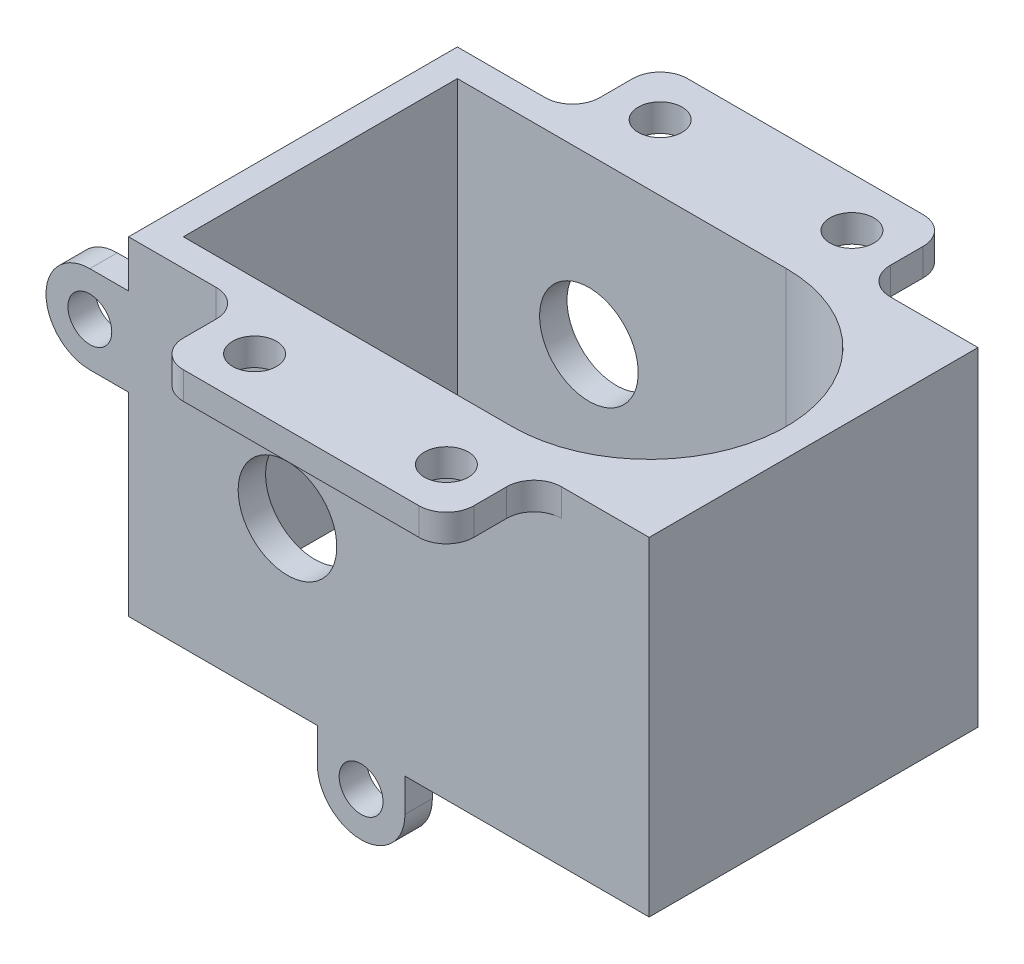
from build123d import *

# Parameters (mm, degrees)
CROQUIS1_W              = 30
CROQUIS1_H              = 30
SALIENTE_EXTRUIR1_DEPTH = 30
CROQUIS2_R              = 12.5
CORTAR_EXTRUIR1_DEPTH   = 30
CROQUIS4_W              = 30
CROQUIS4_H              = 30
SALIENTE_EXTRUIR5_DEPTH = 17.5
CROQUIS6_W              = 30
CROQUIS6_H              = 25
CORTAR_EXTRUIR3_DEPTH   = 37.5
CROQUIS7_R              = 4.5
CORTAR_EXTRUIR5_DEPTH   = 37.5
CROQUIS8_R              = 2
SALIENTE_EXTRUIR6_DEPTH = 2.5
CROQUIS9_W              = 26.5
CROQUIS9_H              = 8
CROQUIS9_R              = 2
SALIENTE_EXTRUIR7_DEPTH = 2.5
REDONDEO1_R             = 2.5


with BuildPart() as part:
    # Croquis1 → Saliente-Extruir1 (new body)
    with BuildSketch(Plane(origin=(0, 0, 0), x_dir=(1, 0, 0), z_dir=(0, 1, 0))):
        Rectangle(CROQUIS1_W, CROQUIS1_H)
    extrude(amount=SALIENTE_EXTRUIR1_DEPTH)

    # Croquis2 → Cortar-Extruir1 (cut)
    with BuildSketch(Plane(origin=(0, 30, 0), x_dir=(1, 0, 0), z_dir=(0, 1, 0))):
        Circle(CROQUIS2_R)
    extrude(amount=-CORTAR_EXTRUIR1_DEPTH, mode=Mode.SUBTRACT)

    # Croquis4 → Saliente-Extruir5 (add)
    with BuildSketch(Plane.ZY.offset(15)):
        with Locations((0, 15)):
            Rectangle(CROQUIS4_W, CROQUIS4_H)
    extrude(amount=SALIENTE_EXTRUIR5_DEPTH)

    # Croquis6 → Cortar-Extruir3 (cut)
    with BuildSketch(Plane(origin=(0, 30, 0), x_dir=(1, 0, 0), z_dir=(0, 1, 0))):
        with Locations((-15, 0)):
            Rectangle(CROQUIS6_W, CROQUIS6_H)
    extrude(amount=-CORTAR_EXTRUIR3_DEPTH, mode=Mode.SUBTRACT)

    # Croquis7 → Cortar-Extruir5 (cut)
    with BuildSketch(Plane(origin=(0, 0, -15), x_dir=(-1, 0, 0), z_dir=(0, 0, -1))):
        with Locations((18, 15)):
            Circle(CROQUIS7_R)
    extrude(amount=-CORTAR_EXTRUIR5_DEPTH, mode=Mode.SUBTRACT)

    # Croquis8 → Saliente-Extruir6 (add)
    with BuildSketch(Plane.XY.offset(15)):
        with BuildLine():
            Line((-36.03122292, 25.717514421), (-32.5, 25.717514421))
            Line((-32.5, 25.717514421), (-32.5, 17.717514421))
            Line((-32.5, 17.717514421), (-36.03122292, 17.717514421))
            ThreePointArc((-36.03122292, 17.717514421), (-40.03122292, 21.717514421), (-36.03122292, 25.717514421))
        make_face()
        with Locations((-36.03122292, 21.717514421)):
            Circle(CROQUIS8_R, mode=Mode.SUBTRACT)
        with BuildLine():
            Line((-15.282485579, -3.03122292), (-15.282485579, 0))
            Line((-15.282485579, 0), (-7.282485579, 0))
            Line((-7.282485579, 0), (-7.282485579, -3.03122292))
            ThreePointArc((-7.282485579, -3.03122292), (-11.282485579, -7.03122292), (-15.282485579, -3.03122292))
        make_face()
        with Locations((-11.282485579, -3.03122292)):
            Circle(CROQUIS8_R, mode=Mode.SUBTRACT)
    extrude(amount=-SALIENTE_EXTRUIR6_DEPTH)

    # Croquis9 → Saliente-Extruir7 (add)
    with BuildSketch(Plane(origin=(0, 30, 0), x_dir=(1, 0, 0), z_dir=(0, 1, 0))):
        with Locations((-8.75, 19)):
            Rectangle(CROQUIS9_W, CROQUIS9_H)
        with Locations((0, 18.5)):
            Circle(CROQUIS9_R, mode=Mode.SUBTRACT)
        with Locations((-17.5, 18.5)):
            Circle(CROQUIS9_R, mode=Mode.SUBTRACT)
        with Locations((-8.75, -19)):
            Rectangle(CROQUIS9_W, CROQUIS9_H)
        with Locations((0, -18.5)):
            Circle(CROQUIS9_R, mode=Mode.SUBTRACT)
        with Locations((-17.5, -18.5)):
            Circle(CROQUIS9_R, mode=Mode.SUBTRACT)
    extrude(amount=-SALIENTE_EXTRUIR7_DEPTH)

    # Redondeo1
    redondeo1_edges = [part.edges().sort_by_distance(p)[0] for p in [
        (-22, 28.75, 23),
        (-22, 28.75, 15),
        (4.5, 28.75, 15),
        (4.5, 28.75, 23),
        (-22, 28.75, -15),
        (-22, 28.75, -23),
        (4.5, 28.75, -23),
        (4.5, 28.75, -15),
    ]]
    fillet(redondeo1_edges, radius=REDONDEO1_R)


solid = part.part
